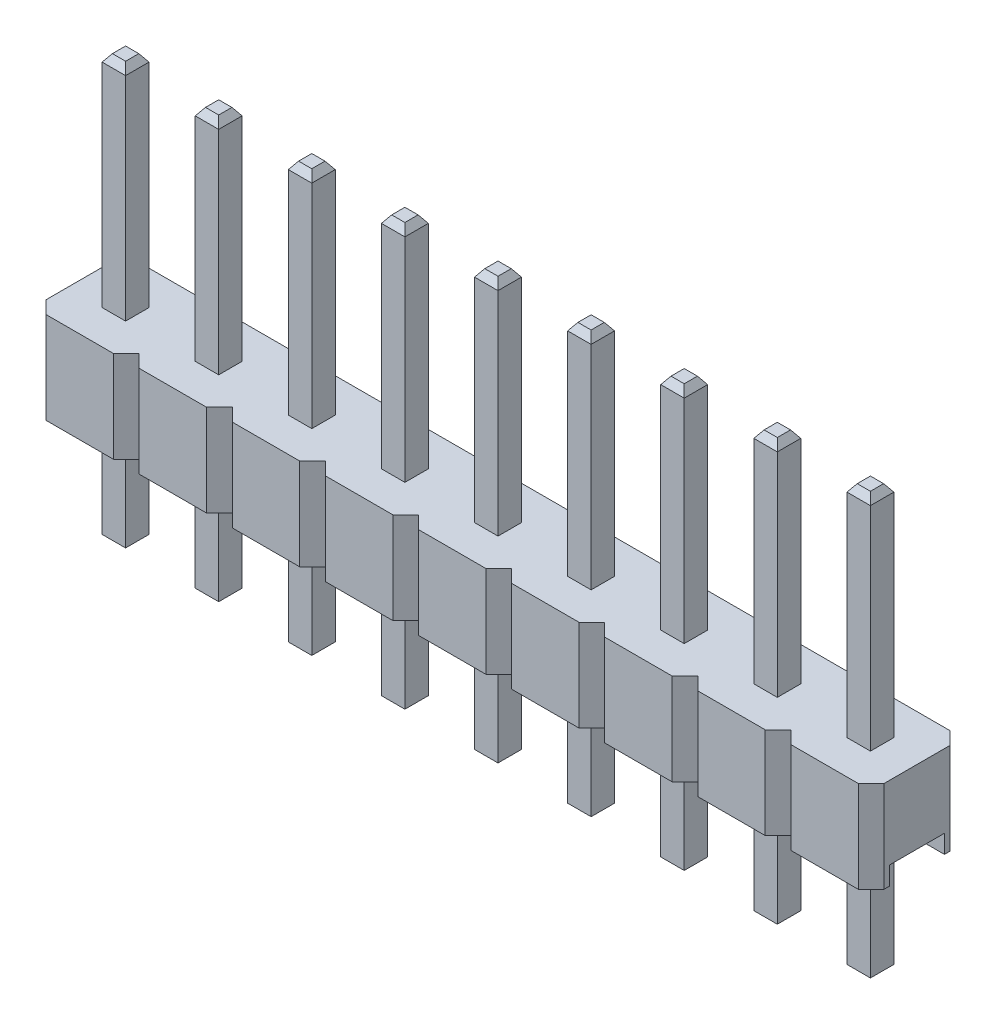
from build123d import *
from OCP.BRepFilletAPI import BRepFilletAPI_MakeChamfer

# Parameters (mm, degrees)
BOSS_EXTRUDE1_DEPTH         = 2.5
SKETCH3_W                   = 2.54
SKETCH3_H                   = 1.5
CUT_EXTRUDE1_DEPTH          = 0.5
BOSS_EXTRUDE2_START         = -5.5
SKETCH4_W                   = 0.64
SKETCH4_H                   = 0.64
BOSS_EXTRUDE2_DEPTH         = 11.5
CHAMFER1_SIZE               = 0.2
CHAMFER1_SIZE2              = 0.140041508
LPATTERN3_COUNT             = 9
LPATTERN3_PITCH             = 2.54
CHAMFER1_OF_LPATTERN3_SIZE  = 0.2
CHAMFER1_OF_LPATTERN3_SIZE2 = 0.140041508


with BuildPart() as part:
    # Sketch1 → Boss-Extrude1 (new body)
    with BuildSketch(Plane(origin=(0, 0, 0), x_dir=(1, 0, 0), z_dir=(0, 1, 0))):
        Polygon((0, 2.15), (0.35, 2.5), (2.19, 2.5), (2.54, 2.15), (2.54, 0.35), (2.19, 0), (0.35, 0), (0, 0.35), align=None)
    boss_extrude1 = extrude(amount=BOSS_EXTRUDE1_DEPTH)

    # Sketch3 → Cut-Extrude1 (cut)
    with BuildSketch(Plane.XZ):
        with Locations((1.27, -1.25)):
            Rectangle(SKETCH3_W, SKETCH3_H)
    cut_extrude1 = extrude(amount=-CUT_EXTRUDE1_DEPTH, mode=Mode.SUBTRACT)

    # Sketch4 → Boss-Extrude2 (add)
    with BuildSketch(Plane(origin=(0, 2.5, 0), x_dir=(1, 0, 0), z_dir=(0, 1, 0)).offset(BOSS_EXTRUDE2_START)):
        with Locations((1.27, 1.25)):
            Rectangle(SKETCH4_W, SKETCH4_H)
    boss_extrude2 = extrude(amount=BOSS_EXTRUDE2_DEPTH)

    # Chamfer1: one chamfer whose edges measure the first distance from different faces: ONE call of the kernel's chamfer builder (chamfer() names one face for all edges)
    chamfer1_edges_1 = [part.edges().sort_by_distance(p)[0] for p in [
        (1.59, -3, -1.25),
        (1.27, -3, -0.93),
        (0.95, -3, -1.25),
        (1.27, -3, -1.57),
    ]]
    chamfer1_side_1 = [part.faces().sort_by_distance(p)[0] for p in [
        (1.27, -3, -1.25),
    ]]
    chamfer1_edges_2 = [part.edges().sort_by_distance(p)[0] for p in [
        (1.59, 8.5, -1.25),
    ]]
    chamfer1_side_2 = [part.faces().sort_by_distance(p)[0] for p in [
        (1.59, 5.5, -1.25),
    ]]
    chamfer1_edges_3 = [part.edges().sort_by_distance(p)[0] for p in [
        (1.27, 8.5, -1.57),
    ]]
    chamfer1_side_3 = [part.faces().sort_by_distance(p)[0] for p in [
        (1.27, 5.5, -1.57),
    ]]
    chamfer1_edges_4 = [part.edges().sort_by_distance(p)[0] for p in [
        (0.95, 8.5, -1.25),
    ]]
    chamfer1_side_4 = [part.faces().sort_by_distance(p)[0] for p in [
        (0.95, 5.5, -1.25),
    ]]
    chamfer1_edges_5 = [part.edges().sort_by_distance(p)[0] for p in [
        (1.27, 8.5, -0.93),
    ]]
    chamfer1_side_5 = [part.faces().sort_by_distance(p)[0] for p in [
        (1.27, 5.5, -0.93),
    ]]
    chamfer1 = BRepFilletAPI_MakeChamfer(part.part.solid().wrapped)
    for e in chamfer1_edges_1:
        chamfer1.Add(CHAMFER1_SIZE, CHAMFER1_SIZE2, e.wrapped, chamfer1_side_1[0].wrapped)  # the first distance lies on this face
    for e in chamfer1_edges_2:
        chamfer1.Add(CHAMFER1_SIZE, CHAMFER1_SIZE2, e.wrapped, chamfer1_side_2[0].wrapped)  # the first distance lies on this face
    for e in chamfer1_edges_3:
        chamfer1.Add(CHAMFER1_SIZE, CHAMFER1_SIZE2, e.wrapped, chamfer1_side_3[0].wrapped)  # the first distance lies on this face
    for e in chamfer1_edges_4:
        chamfer1.Add(CHAMFER1_SIZE, CHAMFER1_SIZE2, e.wrapped, chamfer1_side_4[0].wrapped)  # the first distance lies on this face
    for e in chamfer1_edges_5:
        chamfer1.Add(CHAMFER1_SIZE, CHAMFER1_SIZE2, e.wrapped, chamfer1_side_5[0].wrapped)  # the first distance lies on this face
    add(Compound.cast(chamfer1.Shape()), mode=Mode.REPLACE)

    # LPattern3: Boss-Extrude1, Cut-Extrude1, Boss-Extrude2 ×9
    with Locations(*[(-i * LPATTERN3_PITCH, 0, 0) for i in range(1, LPATTERN3_COUNT)]):
        add(boss_extrude1)
        add(cut_extrude1, mode=Mode.SUBTRACT)
        add(boss_extrude2)

    # Chamfer1 of LPattern3: one chamfer whose edges measure the first distance from different faces: ONE call of the kernel's chamfer builder (chamfer() names one face for all edges)
    chamfer1_of_lpattern3_edges_1 = [part.edges().sort_by_distance(p)[0] for p in [
        (-0.95, -3, -1.25),
        (-1.27, -3, -0.93),
        (-1.59, -3, -1.25),
        (-1.27, -3, -1.57),
    ]]
    chamfer1_of_lpattern3_side_1 = [part.faces().sort_by_distance(p)[0] for p in [
        (-1.27, -3, -1.25),
    ]]
    chamfer1_of_lpattern3_edges_2 = [part.edges().sort_by_distance(p)[0] for p in [
        (-0.95, 8.5, -1.25),
    ]]
    chamfer1_of_lpattern3_side_2 = [part.faces().sort_by_distance(p)[0] for p in [
        (-0.95, 5.5, -1.25),
    ]]
    chamfer1_of_lpattern3_edges_3 = [part.edges().sort_by_distance(p)[0] for p in [
        (-1.27, 8.5, -1.57),
    ]]
    chamfer1_of_lpattern3_side_3 = [part.faces().sort_by_distance(p)[0] for p in [
        (-1.27, 5.5, -1.57),
    ]]
    chamfer1_of_lpattern3_edges_4 = [part.edges().sort_by_distance(p)[0] for p in [
        (-1.59, 8.5, -1.25),
    ]]
    chamfer1_of_lpattern3_side_4 = [part.faces().sort_by_distance(p)[0] for p in [
        (-1.59, 5.5, -1.25),
    ]]
    chamfer1_of_lpattern3_edges_5 = [part.edges().sort_by_distance(p)[0] for p in [
        (-1.27, 8.5, -0.93),
    ]]
    chamfer1_of_lpattern3_side_5 = [part.faces().sort_by_distance(p)[0] for p in [
        (-1.27, 5.5, -0.93),
    ]]
    chamfer1_of_lpattern3_edges_6 = [part.edges().sort_by_distance(p)[0] for p in [
        (-3.49, -3, -1.25),
        (-3.81, -3, -0.93),
        (-4.13, -3, -1.25),
        (-3.81, -3, -1.57),
    ]]
    chamfer1_of_lpattern3_side_6 = [part.faces().sort_by_distance(p)[0] for p in [
        (-3.81, -3, -1.25),
    ]]
    chamfer1_of_lpattern3_edges_7 = [part.edges().sort_by_distance(p)[0] for p in [
        (-3.49, 8.5, -1.25),
    ]]
    chamfer1_of_lpattern3_side_7 = [part.faces().sort_by_distance(p)[0] for p in [
        (-3.49, 5.5, -1.25),
    ]]
    chamfer1_of_lpattern3_edges_8 = [part.edges().sort_by_distance(p)[0] for p in [
        (-3.81, 8.5, -1.57),
    ]]
    chamfer1_of_lpattern3_side_8 = [part.faces().sort_by_distance(p)[0] for p in [
        (-3.81, 5.5, -1.57),
    ]]
    chamfer1_of_lpattern3_edges_9 = [part.edges().sort_by_distance(p)[0] for p in [
        (-4.13, 8.5, -1.25),
    ]]
    chamfer1_of_lpattern3_side_9 = [part.faces().sort_by_distance(p)[0] for p in [
        (-4.13, 5.5, -1.25),
    ]]
    chamfer1_of_lpattern3_edges_10 = [part.edges().sort_by_distance(p)[0] for p in [
        (-3.81, 8.5, -0.93),
    ]]
    chamfer1_of_lpattern3_side_10 = [part.faces().sort_by_distance(p)[0] for p in [
        (-3.81, 5.5, -0.93),
    ]]
    chamfer1_of_lpattern3_edges_11 = [part.edges().sort_by_distance(p)[0] for p in [
        (-6.03, -3, -1.25),
        (-6.35, -3, -0.93),
        (-6.67, -3, -1.25),
        (-6.35, -3, -1.57),
    ]]
    chamfer1_of_lpattern3_side_11 = [part.faces().sort_by_distance(p)[0] for p in [
        (-6.35, -3, -1.25),
    ]]
    chamfer1_of_lpattern3_edges_12 = [part.edges().sort_by_distance(p)[0] for p in [
        (-6.03, 8.5, -1.25),
    ]]
    chamfer1_of_lpattern3_side_12 = [part.faces().sort_by_distance(p)[0] for p in [
        (-6.03, 5.5, -1.25),
    ]]
    chamfer1_of_lpattern3_edges_13 = [part.edges().sort_by_distance(p)[0] for p in [
        (-6.35, 8.5, -1.57),
    ]]
    chamfer1_of_lpattern3_side_13 = [part.faces().sort_by_distance(p)[0] for p in [
        (-6.35, 5.5, -1.57),
    ]]
    chamfer1_of_lpattern3_edges_14 = [part.edges().sort_by_distance(p)[0] for p in [
        (-6.67, 8.5, -1.25),
    ]]
    chamfer1_of_lpattern3_side_14 = [part.faces().sort_by_distance(p)[0] for p in [
        (-6.67, 5.5, -1.25),
    ]]
    chamfer1_of_lpattern3_edges_15 = [part.edges().sort_by_distance(p)[0] for p in [
        (-6.35, 8.5, -0.93),
    ]]
    chamfer1_of_lpattern3_side_15 = [part.faces().sort_by_distance(p)[0] for p in [
        (-6.35, 5.5, -0.93),
    ]]
    chamfer1_of_lpattern3_edges_16 = [part.edges().sort_by_distance(p)[0] for p in [
        (-8.57, -3, -1.25),
        (-8.89, -3, -0.93),
        (-9.21, -3, -1.25),
        (-8.89, -3, -1.57),
    ]]
    chamfer1_of_lpattern3_side_16 = [part.faces().sort_by_distance(p)[0] for p in [
        (-8.89, -3, -1.25),
    ]]
    chamfer1_of_lpattern3_edges_17 = [part.edges().sort_by_distance(p)[0] for p in [
        (-8.57, 8.5, -1.25),
    ]]
    chamfer1_of_lpattern3_side_17 = [part.faces().sort_by_distance(p)[0] for p in [
        (-8.57, 5.5, -1.25),
    ]]
    chamfer1_of_lpattern3_edges_18 = [part.edges().sort_by_distance(p)[0] for p in [
        (-8.89, 8.5, -1.57),
    ]]
    chamfer1_of_lpattern3_side_18 = [part.faces().sort_by_distance(p)[0] for p in [
        (-8.89, 5.5, -1.57),
    ]]
    chamfer1_of_lpattern3_edges_19 = [part.edges().sort_by_distance(p)[0] for p in [
        (-9.21, 8.5, -1.25),
    ]]
    chamfer1_of_lpattern3_side_19 = [part.faces().sort_by_distance(p)[0] for p in [
        (-9.21, 5.5, -1.25),
    ]]
    chamfer1_of_lpattern3_edges_20 = [part.edges().sort_by_distance(p)[0] for p in [
        (-8.89, 8.5, -0.93),
    ]]
    chamfer1_of_lpattern3_side_20 = [part.faces().sort_by_distance(p)[0] for p in [
        (-8.89, 5.5, -0.93),
    ]]
    chamfer1_of_lpattern3_edges_21 = [part.edges().sort_by_distance(p)[0] for p in [
        (-11.11, -3, -1.25),
        (-11.43, -3, -0.93),
        (-11.75, -3, -1.25),
        (-11.43, -3, -1.57),
    ]]
    chamfer1_of_lpattern3_side_21 = [part.faces().sort_by_distance(p)[0] for p in [
        (-11.43, -3, -1.25),
    ]]
    chamfer1_of_lpattern3_edges_22 = [part.edges().sort_by_distance(p)[0] for p in [
        (-11.11, 8.5, -1.25),
    ]]
    chamfer1_of_lpattern3_side_22 = [part.faces().sort_by_distance(p)[0] for p in [
        (-11.11, 5.5, -1.25),
    ]]
    chamfer1_of_lpattern3_edges_23 = [part.edges().sort_by_distance(p)[0] for p in [
        (-11.43, 8.5, -1.57),
    ]]
    chamfer1_of_lpattern3_side_23 = [part.faces().sort_by_distance(p)[0] for p in [
        (-11.43, 5.5, -1.57),
    ]]
    chamfer1_of_lpattern3_edges_24 = [part.edges().sort_by_distance(p)[0] for p in [
        (-11.75, 8.5, -1.25),
    ]]
    chamfer1_of_lpattern3_side_24 = [part.faces().sort_by_distance(p)[0] for p in [
        (-11.75, 5.5, -1.25),
    ]]
    chamfer1_of_lpattern3_edges_25 = [part.edges().sort_by_distance(p)[0] for p in [
        (-11.43, 8.5, -0.93),
    ]]
    chamfer1_of_lpattern3_side_25 = [part.faces().sort_by_distance(p)[0] for p in [
        (-11.43, 5.5, -0.93),
    ]]
    chamfer1_of_lpattern3_edges_26 = [part.edges().sort_by_distance(p)[0] for p in [
        (-13.65, -3, -1.25),
        (-13.97, -3, -0.93),
        (-14.29, -3, -1.25),
        (-13.97, -3, -1.57),
    ]]
    chamfer1_of_lpattern3_side_26 = [part.faces().sort_by_distance(p)[0] for p in [
        (-13.97, -3, -1.25),
    ]]
    chamfer1_of_lpattern3_edges_27 = [part.edges().sort_by_distance(p)[0] for p in [
        (-13.65, 8.5, -1.25),
    ]]
    chamfer1_of_lpattern3_side_27 = [part.faces().sort_by_distance(p)[0] for p in [
        (-13.65, 5.5, -1.25),
    ]]
    chamfer1_of_lpattern3_edges_28 = [part.edges().sort_by_distance(p)[0] for p in [
        (-13.97, 8.5, -1.57),
    ]]
    chamfer1_of_lpattern3_side_28 = [part.faces().sort_by_distance(p)[0] for p in [
        (-13.97, 5.5, -1.57),
    ]]
    chamfer1_of_lpattern3_edges_29 = [part.edges().sort_by_distance(p)[0] for p in [
        (-14.29, 8.5, -1.25),
    ]]
    chamfer1_of_lpattern3_side_29 = [part.faces().sort_by_distance(p)[0] for p in [
        (-14.29, 5.5, -1.25),
    ]]
    chamfer1_of_lpattern3_edges_30 = [part.edges().sort_by_distance(p)[0] for p in [
        (-13.97, 8.5, -0.93),
    ]]
    chamfer1_of_lpattern3_side_30 = [part.faces().sort_by_distance(p)[0] for p in [
        (-13.97, 5.5, -0.93),
    ]]
    chamfer1_of_lpattern3_edges_31 = [part.edges().sort_by_distance(p)[0] for p in [
        (-16.19, -3, -1.25),
        (-16.51, -3, -0.93),
        (-16.83, -3, -1.25),
        (-16.51, -3, -1.57),
    ]]
    chamfer1_of_lpattern3_side_31 = [part.faces().sort_by_distance(p)[0] for p in [
        (-16.51, -3, -1.25),
    ]]
    chamfer1_of_lpattern3_edges_32 = [part.edges().sort_by_distance(p)[0] for p in [
        (-16.19, 8.5, -1.25),
    ]]
    chamfer1_of_lpattern3_side_32 = [part.faces().sort_by_distance(p)[0] for p in [
        (-16.19, 5.5, -1.25),
    ]]
    chamfer1_of_lpattern3_edges_33 = [part.edges().sort_by_distance(p)[0] for p in [
        (-16.51, 8.5, -1.57),
    ]]
    chamfer1_of_lpattern3_side_33 = [part.faces().sort_by_distance(p)[0] for p in [
        (-16.51, 5.5, -1.57),
    ]]
    chamfer1_of_lpattern3_edges_34 = [part.edges().sort_by_distance(p)[0] for p in [
        (-16.83, 8.5, -1.25),
    ]]
    chamfer1_of_lpattern3_side_34 = [part.faces().sort_by_distance(p)[0] for p in [
        (-16.83, 5.5, -1.25),
    ]]
    chamfer1_of_lpattern3_edges_35 = [part.edges().sort_by_distance(p)[0] for p in [
        (-16.51, 8.5, -0.93),
    ]]
    chamfer1_of_lpattern3_side_35 = [part.faces().sort_by_distance(p)[0] for p in [
        (-16.51, 5.5, -0.93),
    ]]
    chamfer1_of_lpattern3_edges_36 = [part.edges().sort_by_distance(p)[0] for p in [
        (-18.73, -3, -1.25),
        (-19.05, -3, -0.93),
        (-19.37, -3, -1.25),
        (-19.05, -3, -1.57),
    ]]
    chamfer1_of_lpattern3_side_36 = [part.faces().sort_by_distance(p)[0] for p in [
        (-19.05, -3, -1.25),
    ]]
    chamfer1_of_lpattern3_edges_37 = [part.edges().sort_by_distance(p)[0] for p in [
        (-18.73, 8.5, -1.25),
    ]]
    chamfer1_of_lpattern3_side_37 = [part.faces().sort_by_distance(p)[0] for p in [
        (-18.73, 5.5, -1.25),
    ]]
    chamfer1_of_lpattern3_edges_38 = [part.edges().sort_by_distance(p)[0] for p in [
        (-19.05, 8.5, -1.57),
    ]]
    chamfer1_of_lpattern3_side_38 = [part.faces().sort_by_distance(p)[0] for p in [
        (-19.05, 5.5, -1.57),
    ]]
    chamfer1_of_lpattern3_edges_39 = [part.edges().sort_by_distance(p)[0] for p in [
        (-19.37, 8.5, -1.25),
    ]]
    chamfer1_of_lpattern3_side_39 = [part.faces().sort_by_distance(p)[0] for p in [
        (-19.37, 5.5, -1.25),
    ]]
    chamfer1_of_lpattern3_edges_40 = [part.edges().sort_by_distance(p)[0] for p in [
        (-19.05, 8.5, -0.93),
    ]]
    chamfer1_of_lpattern3_side_40 = [part.faces().sort_by_distance(p)[0] for p in [
        (-19.05, 5.5, -0.93),
    ]]
    chamfer1_of_lpattern3 = BRepFilletAPI_MakeChamfer(part.part.solid().wrapped)
    for e in chamfer1_of_lpattern3_edges_1:
        chamfer1_of_lpattern3.Add(CHAMFER1_OF_LPATTERN3_SIZE, CHAMFER1_OF_LPATTERN3_SIZE2, e.wrapped, chamfer1_of_lpattern3_side_1[0].wrapped)  # the first distance lies on this face
    for e in chamfer1_of_lpattern3_edges_2:
        chamfer1_of_lpattern3.Add(CHAMFER1_OF_LPATTERN3_SIZE, CHAMFER1_OF_LPATTERN3_SIZE2, e.wrapped, chamfer1_of_lpattern3_side_2[0].wrapped)  # the first distance lies on this face
    for e in chamfer1_of_lpattern3_edges_3:
        chamfer1_of_lpattern3.Add(CHAMFER1_OF_LPATTERN3_SIZE, CHAMFER1_OF_LPATTERN3_SIZE2, e.wrapped, chamfer1_of_lpattern3_side_3[0].wrapped)  # the first distance lies on this face
    for e in chamfer1_of_lpattern3_edges_4:
        chamfer1_of_lpattern3.Add(CHAMFER1_OF_LPATTERN3_SIZE, CHAMFER1_OF_LPATTERN3_SIZE2, e.wrapped, chamfer1_of_lpattern3_side_4[0].wrapped)  # the first distance lies on this face
    for e in chamfer1_of_lpattern3_edges_5:
        chamfer1_of_lpattern3.Add(CHAMFER1_OF_LPATTERN3_SIZE, CHAMFER1_OF_LPATTERN3_SIZE2, e.wrapped, chamfer1_of_lpattern3_side_5[0].wrapped)  # the first distance lies on this face
    for e in chamfer1_of_lpattern3_edges_6:
        chamfer1_of_lpattern3.Add(CHAMFER1_OF_LPATTERN3_SIZE, CHAMFER1_OF_LPATTERN3_SIZE2, e.wrapped, chamfer1_of_lpattern3_side_6[0].wrapped)  # the first distance lies on this face
    for e in chamfer1_of_lpattern3_edges_7:
        chamfer1_of_lpattern3.Add(CHAMFER1_OF_LPATTERN3_SIZE, CHAMFER1_OF_LPATTERN3_SIZE2, e.wrapped, chamfer1_of_lpattern3_side_7[0].wrapped)  # the first distance lies on this face
    for e in chamfer1_of_lpattern3_edges_8:
        chamfer1_of_lpattern3.Add(CHAMFER1_OF_LPATTERN3_SIZE, CHAMFER1_OF_LPATTERN3_SIZE2, e.wrapped, chamfer1_of_lpattern3_side_8[0].wrapped)  # the first distance lies on this face
    for e in chamfer1_of_lpattern3_edges_9:
        chamfer1_of_lpattern3.Add(CHAMFER1_OF_LPATTERN3_SIZE, CHAMFER1_OF_LPATTERN3_SIZE2, e.wrapped, chamfer1_of_lpattern3_side_9[0].wrapped)  # the first distance lies on this face
    for e in chamfer1_of_lpattern3_edges_10:
        chamfer1_of_lpattern3.Add(CHAMFER1_OF_LPATTERN3_SIZE, CHAMFER1_OF_LPATTERN3_SIZE2, e.wrapped, chamfer1_of_lpattern3_side_10[0].wrapped)  # the first distance lies on this face
    for e in chamfer1_of_lpattern3_edges_11:
        chamfer1_of_lpattern3.Add(CHAMFER1_OF_LPATTERN3_SIZE, CHAMFER1_OF_LPATTERN3_SIZE2, e.wrapped, chamfer1_of_lpattern3_side_11[0].wrapped)  # the first distance lies on this face
    for e in chamfer1_of_lpattern3_edges_12:
        chamfer1_of_lpattern3.Add(CHAMFER1_OF_LPATTERN3_SIZE, CHAMFER1_OF_LPATTERN3_SIZE2, e.wrapped, chamfer1_of_lpattern3_side_12[0].wrapped)  # the first distance lies on this face
    for e in chamfer1_of_lpattern3_edges_13:
        chamfer1_of_lpattern3.Add(CHAMFER1_OF_LPATTERN3_SIZE, CHAMFER1_OF_LPATTERN3_SIZE2, e.wrapped, chamfer1_of_lpattern3_side_13[0].wrapped)  # the first distance lies on this face
    for e in chamfer1_of_lpattern3_edges_14:
        chamfer1_of_lpattern3.Add(CHAMFER1_OF_LPATTERN3_SIZE, CHAMFER1_OF_LPATTERN3_SIZE2, e.wrapped, chamfer1_of_lpattern3_side_14[0].wrapped)  # the first distance lies on this face
    for e in chamfer1_of_lpattern3_edges_15:
        chamfer1_of_lpattern3.Add(CHAMFER1_OF_LPATTERN3_SIZE, CHAMFER1_OF_LPATTERN3_SIZE2, e.wrapped, chamfer1_of_lpattern3_side_15[0].wrapped)  # the first distance lies on this face
    for e in chamfer1_of_lpattern3_edges_16:
        chamfer1_of_lpattern3.Add(CHAMFER1_OF_LPATTERN3_SIZE, CHAMFER1_OF_LPATTERN3_SIZE2, e.wrapped, chamfer1_of_lpattern3_side_16[0].wrapped)  # the first distance lies on this face
    for e in chamfer1_of_lpattern3_edges_17:
        chamfer1_of_lpattern3.Add(CHAMFER1_OF_LPATTERN3_SIZE, CHAMFER1_OF_LPATTERN3_SIZE2, e.wrapped, chamfer1_of_lpattern3_side_17[0].wrapped)  # the first distance lies on this face
    for e in chamfer1_of_lpattern3_edges_18:
        chamfer1_of_lpattern3.Add(CHAMFER1_OF_LPATTERN3_SIZE, CHAMFER1_OF_LPATTERN3_SIZE2, e.wrapped, chamfer1_of_lpattern3_side_18[0].wrapped)  # the first distance lies on this face
    for e in chamfer1_of_lpattern3_edges_19:
        chamfer1_of_lpattern3.Add(CHAMFER1_OF_LPATTERN3_SIZE, CHAMFER1_OF_LPATTERN3_SIZE2, e.wrapped, chamfer1_of_lpattern3_side_19[0].wrapped)  # the first distance lies on this face
    for e in chamfer1_of_lpattern3_edges_20:
        chamfer1_of_lpattern3.Add(CHAMFER1_OF_LPATTERN3_SIZE, CHAMFER1_OF_LPATTERN3_SIZE2, e.wrapped, chamfer1_of_lpattern3_side_20[0].wrapped)  # the first distance lies on this face
    for e in chamfer1_of_lpattern3_edges_21:
        chamfer1_of_lpattern3.Add(CHAMFER1_OF_LPATTERN3_SIZE, CHAMFER1_OF_LPATTERN3_SIZE2, e.wrapped, chamfer1_of_lpattern3_side_21[0].wrapped)  # the first distance lies on this face
    for e in chamfer1_of_lpattern3_edges_22:
        chamfer1_of_lpattern3.Add(CHAMFER1_OF_LPATTERN3_SIZE, CHAMFER1_OF_LPATTERN3_SIZE2, e.wrapped, chamfer1_of_lpattern3_side_22[0].wrapped)  # the first distance lies on this face
    for e in chamfer1_of_lpattern3_edges_23:
        chamfer1_of_lpattern3.Add(CHAMFER1_OF_LPATTERN3_SIZE, CHAMFER1_OF_LPATTERN3_SIZE2, e.wrapped, chamfer1_of_lpattern3_side_23[0].wrapped)  # the first distance lies on this face
    for e in chamfer1_of_lpattern3_edges_24:
        chamfer1_of_lpattern3.Add(CHAMFER1_OF_LPATTERN3_SIZE, CHAMFER1_OF_LPATTERN3_SIZE2, e.wrapped, chamfer1_of_lpattern3_side_24[0].wrapped)  # the first distance lies on this face
    for e in chamfer1_of_lpattern3_edges_25:
        chamfer1_of_lpattern3.Add(CHAMFER1_OF_LPATTERN3_SIZE, CHAMFER1_OF_LPATTERN3_SIZE2, e.wrapped, chamfer1_of_lpattern3_side_25[0].wrapped)  # the first distance lies on this face
    for e in chamfer1_of_lpattern3_edges_26:
        chamfer1_of_lpattern3.Add(CHAMFER1_OF_LPATTERN3_SIZE, CHAMFER1_OF_LPATTERN3_SIZE2, e.wrapped, chamfer1_of_lpattern3_side_26[0].wrapped)  # the first distance lies on this face
    for e in chamfer1_of_lpattern3_edges_27:
        chamfer1_of_lpattern3.Add(CHAMFER1_OF_LPATTERN3_SIZE, CHAMFER1_OF_LPATTERN3_SIZE2, e.wrapped, chamfer1_of_lpattern3_side_27[0].wrapped)  # the first distance lies on this face
    for e in chamfer1_of_lpattern3_edges_28:
        chamfer1_of_lpattern3.Add(CHAMFER1_OF_LPATTERN3_SIZE, CHAMFER1_OF_LPATTERN3_SIZE2, e.wrapped, chamfer1_of_lpattern3_side_28[0].wrapped)  # the first distance lies on this face
    for e in chamfer1_of_lpattern3_edges_29:
        chamfer1_of_lpattern3.Add(CHAMFER1_OF_LPATTERN3_SIZE, CHAMFER1_OF_LPATTERN3_SIZE2, e.wrapped, chamfer1_of_lpattern3_side_29[0].wrapped)  # the first distance lies on this face
    for e in chamfer1_of_lpattern3_edges_30:
        chamfer1_of_lpattern3.Add(CHAMFER1_OF_LPATTERN3_SIZE, CHAMFER1_OF_LPATTERN3_SIZE2, e.wrapped, chamfer1_of_lpattern3_side_30[0].wrapped)  # the first distance lies on this face
    for e in chamfer1_of_lpattern3_edges_31:
        chamfer1_of_lpattern3.Add(CHAMFER1_OF_LPATTERN3_SIZE, CHAMFER1_OF_LPATTERN3_SIZE2, e.wrapped, chamfer1_of_lpattern3_side_31[0].wrapped)  # the first distance lies on this face
    for e in chamfer1_of_lpattern3_edges_32:
        chamfer1_of_lpattern3.Add(CHAMFER1_OF_LPATTERN3_SIZE, CHAMFER1_OF_LPATTERN3_SIZE2, e.wrapped, chamfer1_of_lpattern3_side_32[0].wrapped)  # the first distance lies on this face
    for e in chamfer1_of_lpattern3_edges_33:
        chamfer1_of_lpattern3.Add(CHAMFER1_OF_LPATTERN3_SIZE, CHAMFER1_OF_LPATTERN3_SIZE2, e.wrapped, chamfer1_of_lpattern3_side_33[0].wrapped)  # the first distance lies on this face
    for e in chamfer1_of_lpattern3_edges_34:
        chamfer1_of_lpattern3.Add(CHAMFER1_OF_LPATTERN3_SIZE, CHAMFER1_OF_LPATTERN3_SIZE2, e.wrapped, chamfer1_of_lpattern3_side_34[0].wrapped)  # the first distance lies on this face
    for e in chamfer1_of_lpattern3_edges_35:
        chamfer1_of_lpattern3.Add(CHAMFER1_OF_LPATTERN3_SIZE, CHAMFER1_OF_LPATTERN3_SIZE2, e.wrapped, chamfer1_of_lpattern3_side_35[0].wrapped)  # the first distance lies on this face
    for e in chamfer1_of_lpattern3_edges_36:
        chamfer1_of_lpattern3.Add(CHAMFER1_OF_LPATTERN3_SIZE, CHAMFER1_OF_LPATTERN3_SIZE2, e.wrapped, chamfer1_of_lpattern3_side_36[0].wrapped)  # the first distance lies on this face
    for e in chamfer1_of_lpattern3_edges_37:
        chamfer1_of_lpattern3.Add(CHAMFER1_OF_LPATTERN3_SIZE, CHAMFER1_OF_LPATTERN3_SIZE2, e.wrapped, chamfer1_of_lpattern3_side_37[0].wrapped)  # the first distance lies on this face
    for e in chamfer1_of_lpattern3_edges_38:
        chamfer1_of_lpattern3.Add(CHAMFER1_OF_LPATTERN3_SIZE, CHAMFER1_OF_LPATTERN3_SIZE2, e.wrapped, chamfer1_of_lpattern3_side_38[0].wrapped)  # the first distance lies on this face
    for e in chamfer1_of_lpattern3_edges_39:
        chamfer1_of_lpattern3.Add(CHAMFER1_OF_LPATTERN3_SIZE, CHAMFER1_OF_LPATTERN3_SIZE2, e.wrapped, chamfer1_of_lpattern3_side_39[0].wrapped)  # the first distance lies on this face
    for e in chamfer1_of_lpattern3_edges_40:
        chamfer1_of_lpattern3.Add(CHAMFER1_OF_LPATTERN3_SIZE, CHAMFER1_OF_LPATTERN3_SIZE2, e.wrapped, chamfer1_of_lpattern3_side_40[0].wrapped)  # the first distance lies on this face
    add(Compound.cast(chamfer1_of_lpattern3.Shape()), mode=Mode.REPLACE)


solid = part.part
